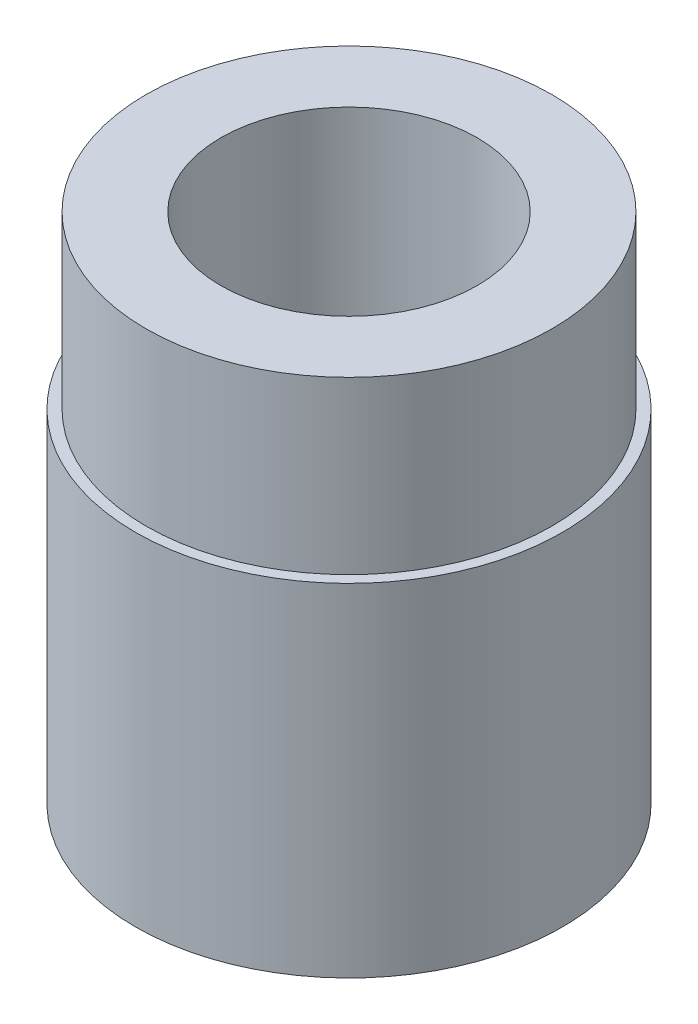
from build123d import *

# Parameters (mm, degrees)
SKETCH1_R           = 31.75
SKETCH1_R_2         = 19.05
BOSS_EXTRUDE1_DEPTH = 76.2
SKETCH3_R           = 31.75
SKETCH3_R_2         = 30.1625
CUT_EXTRUDE1_DEPTH  = 25.4


with BuildPart() as part:
    # Sketch1 → Boss-Extrude1 (new body)
    with BuildSketch(Plane(origin=(0, 0, 0), x_dir=(1, 0, 0), z_dir=(0, 1, 0))):
        Circle(SKETCH1_R)
        Circle(SKETCH1_R_2, mode=Mode.SUBTRACT)
    extrude(amount=BOSS_EXTRUDE1_DEPTH)

    # Sketch3 → Cut-Extrude1 (cut)
    with BuildSketch(Plane(origin=(0, 76.2, 0), x_dir=(1, 0, 0), z_dir=(0, 1, 0))):
        Circle(SKETCH3_R)
        Circle(SKETCH3_R_2, mode=Mode.SUBTRACT)
    extrude(amount=-CUT_EXTRUDE1_DEPTH, mode=Mode.SUBTRACT)


solid = part.part
